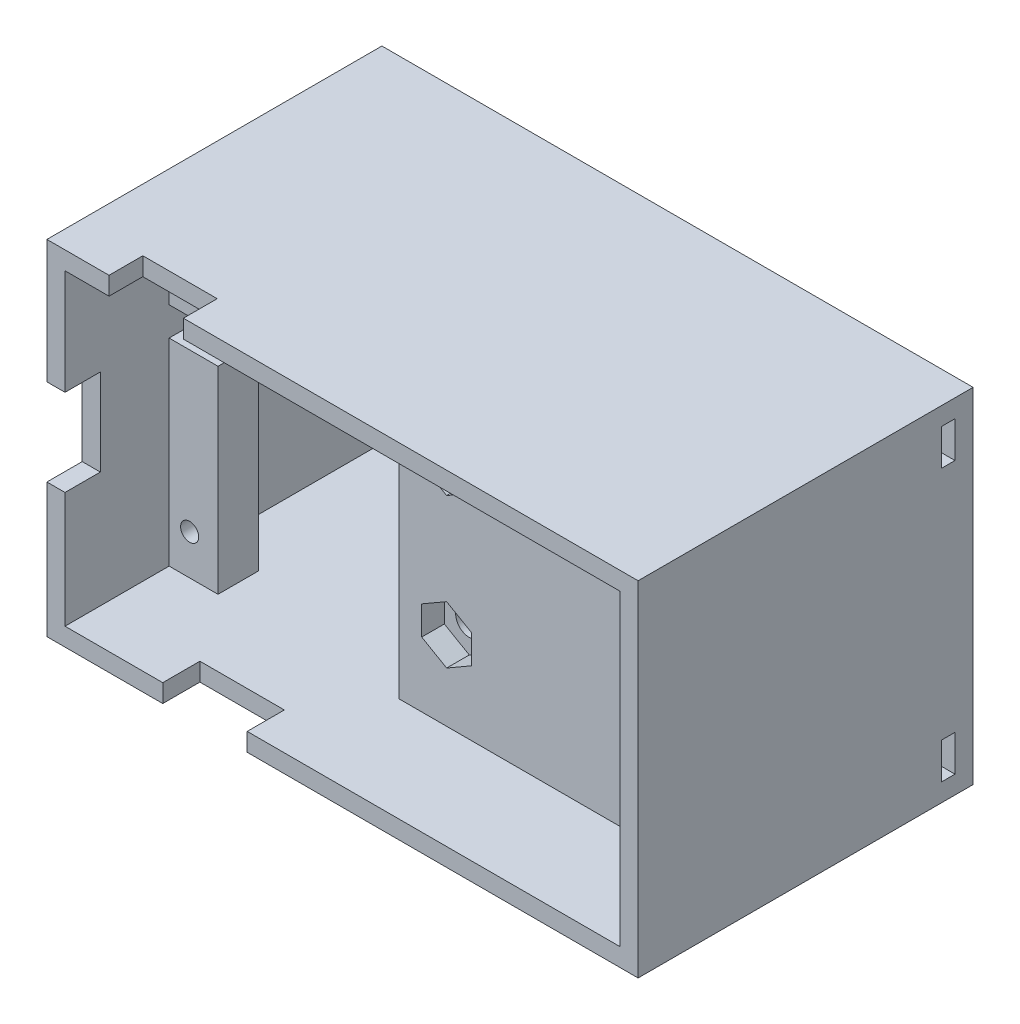
from build123d import *

# Parameters (mm, degrees)
SKETCH_2_W           = 65.2997206
SKETCH_2_H           = 38
SKETCH_2_R           = 1.00000254
SKETCH_2_R_2         = 0.922218434
SKETCH_2_R_3         = 1.5
EXTRUDE_2_DEPTH      = 4.5
SKETCH_3_R           = 1.5
CUT_EXTRUDE_2_DEPTH  = 2.5
SKETCH_5_W           = 65.2997206
SKETCH_5_H           = 38
SKETCH_5_W_2         = 61.2997206
SKETCH_5_H_2         = 34
EXTRUDE_3_DEPTH      = 21
EXTRUDE_3_DEPTH_BACK = 16
SKETCH_7_W           = 8.214112973
SKETCH_7_H           = 3.795011114
CUT_EXTRUDE_4_DEPTH  = 3
SKETCH_8_W           = 4
SKETCH_8_H           = 9.575559499
CUT_EXTRUDE_5_DEPTH  = 3
SKETCH_9_W           = 9.326303795
SKETCH_9_H           = 4.202278939
CUT_EXTRUDE_6_DEPTH  = 3
CUT_EXTRUDE_7_DEPTH  = 10
SKETCH_15_R          = 1.75
CUT_EXTRUDE_8_DEPTH  = 1.5
SKETCH_18_W          = 61.2997206
SKETCH_18_H          = 35
CUT_EXTRUDE_9_DEPTH  = 2
SKETCH_19_W          = 1.5
SKETCH_19_H          = 4
CUT_EXTRUDE_10_DEPTH = 2


with BuildPart() as part:
    # 草图2 → 凸台-拉伸2 (new body)
    with BuildSketch(Plane(origin=(0, 0, -6), x_dir=(-1, 0, 0), z_dir=(0, 0, -1))):
        with Locations((29.273558547, -24.066548133)):
            Rectangle(SKETCH_2_W, SKETCH_2_H)
        with Locations((1.016002032, -11.24978156)):
            Circle(SKETCH_2_R, mode=Mode.SUBTRACT)
        with Locations((0.889001778, -36.83007366)):
            Circle(SKETCH_2_R, mode=Mode.SUBTRACT)
        with Locations((57.658115316, -36.64983236)):
            Circle(SKETCH_2_R, mode=Mode.SUBTRACT)
        with Locations((57.658115316, -11.24978156)):
            Circle(SKETCH_2_R_2, mode=Mode.SUBTRACT)
        with Locations((29.273558547, -32.316548133)):
            Circle(SKETCH_2_R_3, mode=Mode.SUBTRACT)
        with BuildLine():
            Line((27.785407033, -15.816548133), (27.785407033, -13.183619987))
            ThreePointArc((27.785407033, -13.183619987), (29.273558547, -11.695468472), (30.761710061, -13.183619987))
            Line((30.761710061, -13.183619987), (30.761710061, -15.816548133))
            ThreePointArc((30.761710061, -15.816548133), (29.273558547, -17.304699647), (27.785407033, -15.816548133))
        make_face(mode=Mode.SUBTRACT)
    extrude(amount=EXTRUDE_2_DEPTH)

    # 草图3 → 切除-拉伸2 (cut)
    with BuildSketch(Plane(origin=(0, 0, -6), x_dir=(-1, 0, 0), z_dir=(0, 0, -1))):
        Polygon((29.273558547, -18.991974614), (32.023558547, -17.404261373), (32.023558547, -14.920341582), (32.023558547, -14.228834893), (32.023558547, -11.744915102), (29.273558547, -10.157201862), (26.523558547, -11.744915102), (26.523558547, -14.228834893), (26.523558547, -14.920341582), (26.523558547, -17.404261373), align=None)
        with BuildLine():
            ThreePointArc((30.761710061, -15.816548133), (29.273558547, -17.304699647), (27.785407033, -15.816548133))
            Line((27.785407033, -15.816548133), (27.785407033, -13.183619987))
            ThreePointArc((27.785407033, -13.183619987), (29.273558547, -11.695468472), (30.761710061, -13.183619987))
            Line((30.761710061, -13.183619987), (30.761710061, -15.816548133))
        make_face(mode=Mode.SUBTRACT)
        Polygon((26.523558547, -30.728834893), (26.523558547, -33.904261373), (29.273558547, -35.491974614), (32.023558547, -33.904261373), (32.023558547, -30.728834893), (29.273558547, -29.141121653), align=None)
        with Locations((29.273558547, -32.316548133)):
            Circle(SKETCH_3_R, mode=Mode.SUBTRACT)
    extrude(amount=CUT_EXTRUDE_2_DEPTH, mode=Mode.SUBTRACT)

    # 草图5 → 凸台-拉伸3 (add, two sides)
    with BuildSketch(Plane(origin=(0, 0, -10.5), x_dir=(-1, 0, 0), z_dir=(0, 0, -1))) as extrude_3_sk:
        with Locations((29.273558547, -24.066548133)):
            Rectangle(SKETCH_5_W, SKETCH_5_H)
        with Locations((29.273558547, -24.066548133)):
            Rectangle(SKETCH_5_W_2, SKETCH_5_H_2, mode=Mode.SUBTRACT)
    extrude(amount=EXTRUDE_3_DEPTH)
    extrude(extrude_3_sk.sketch, amount=-EXTRUDE_3_DEPTH_BACK)

    # 草图7 → 切除-拉伸4 (cut)
    with BuildSketch(Plane(origin=(0, -5.066548133, 0), x_dir=(1, 0, 0), z_dir=(0, 1, 0))):
        with Locations((-50.955145133, -3.662545243)):
            Rectangle(SKETCH_7_W, SKETCH_7_H)
    extrude(amount=-CUT_EXTRUDE_4_DEPTH, mode=Mode.SUBTRACT)

    # 草图8 → 切除-拉伸5 (cut)
    with BuildSketch(Plane.ZY.offset(61.923418847)):
        with Locations((3.6000508, -23.483057223)):
            Rectangle(SKETCH_8_W, SKETCH_8_H)
    extrude(amount=-CUT_EXTRUDE_5_DEPTH, mode=Mode.SUBTRACT)

    # 草图9 → 切除-拉伸6 (cut)
    with BuildSketch(Plane.XZ.offset(43.066548133)):
        with Locations((-44.464129124, 3.49891133)):
            Rectangle(SKETCH_9_W, SKETCH_9_H)
    extrude(amount=-CUT_EXTRUDE_6_DEPTH, mode=Mode.SUBTRACT)

    # 草图13 → 切除-拉伸7 (cut)
    with BuildSketch(Plane.XY.offset(-6)):
        Polygon((-59.923418847, -16.066514367), (-59.923418847, -19.252115931), (-54.525349934, -19.252115931), (-54.525349934, -41.066548133), (-34.525349934, -41.066548133), (-34.525349934, -7.066548133), (-54.525349934, -7.066548133), (-54.525349934, -12.880912803), (-54.525349934, -16.066514367), align=None)
    extrude(amount=-CUT_EXTRUDE_7_DEPTH, mode=Mode.SUBTRACT)

    # 草图15 → 切除-拉伸8 (cut)
    with BuildSketch(Plane(origin=(0, 0, -10.5), x_dir=(-1, 0, 0), z_dir=(0, 0, -1))):
        with Locations((1.016002032, -11.24978156)):
            Circle(SKETCH_15_R)
        with Locations((57.658115316, -11.24978156)):
            Circle(SKETCH_15_R)
        with Locations((0.889001778, -36.83007366)):
            Circle(SKETCH_15_R)
        with Locations((57.658115316, -36.64983236)):
            Circle(SKETCH_15_R)
    extrude(amount=-CUT_EXTRUDE_8_DEPTH, mode=Mode.SUBTRACT)

    # 草图18 → 切除-拉伸9 (cut)
    with BuildSketch(Plane(origin=(0, 0, -31.5), x_dir=(-1, 0, 0), z_dir=(0, 0, -1))):
        with Locations((29.273558547, -24.066548133)):
            Rectangle(SKETCH_18_W, SKETCH_18_H)
    extrude(amount=-CUT_EXTRUDE_9_DEPTH, mode=Mode.SUBTRACT)

    # 草图19 → 切除-拉伸10 (cut)
    with BuildSketch(Plane.ZY.offset(-1.376301753)):
        with Locations((-28.75, -9.066548133)):
            Rectangle(SKETCH_19_W, SKETCH_19_H)
        with Locations((-28.75, -39.066548133)):
            Rectangle(SKETCH_19_W, SKETCH_19_H)
    extrude(amount=-CUT_EXTRUDE_10_DEPTH, mode=Mode.SUBTRACT)


solid = part.part
